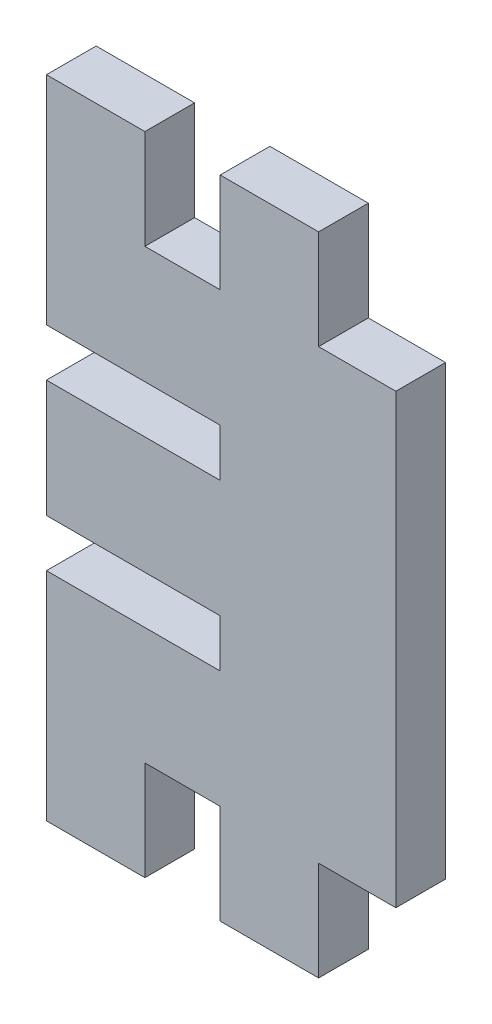
from build123d import *

# Parameters (mm, degrees)
BOSS_EXTRUDE1_DEPTH = 5.15


with BuildPart() as part:
    # Sketch1 → Boss-Extrude1 (new body)
    with BuildSketch(Plane.XY):
        Polygon((-0.1, -6.075), (-0.1, -11.025), (-18.1, -11.025), (-18.1, -33.475), (-7.9, -33.475), (-7.9, -23.175), (-0.1, -23.175), (-0.1, -33.475), (10.1, -33.475), (10.1, -23.175), (18.1, -23.175), (18.1, 23.175), (10.1, 23.175), (10.1, 33.475), (-0.1, 33.475), (-0.1, 23.175), (-7.9, 23.175), (-7.9, 33.475), (-18.1, 33.475), (-18.1, 11.025), (-0.1, 11.025), (-0.1, 6.075), (-18.1, 6.075), (-18.1, -6.075), align=None)
    extrude(amount=BOSS_EXTRUDE1_DEPTH)


solid = part.part
